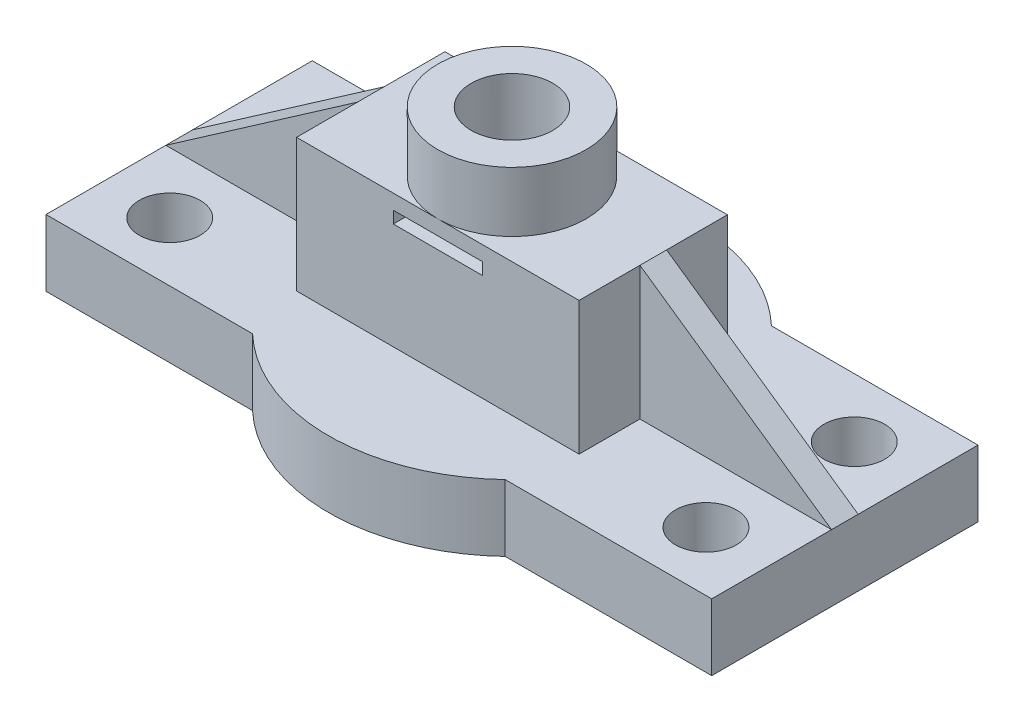
from build123d import *

# Parameters (mm, degrees)
SKETCH2_R           = 4.566933549
BOSS_EXTRUDE1_DEPTH = 10
SKETCH3_W           = 42.436263922
SKETCH3_H           = 22.27820436
BOSS_EXTRUDE2_DEPTH = 20
RIB2_REACH          = 66.498
SKETCH5_WALL_W      = 166.044941872
SKETCH5_WALL_H      = 4
BOSS_EXTRUDE3_DEPTH = 2
SKETCH7_R           = 11.13910218
SKETCH7_R_2         = 6.13910218
EXTRUDE_THIN1_DEPTH = 9
SKETCH9_R           = 6.13910218
CUT_EXTRUDE2_DEPTH  = 65.498231097
SKETCH12_R          = 10
CUT_EXTRUDE4_DEPTH  = 19
CUT_EXTRUDE4_DRAFT  = -11.5
SKETCH13_W          = 13.380488588
SKETCH13_H          = 1.799910433
CUT_EXTRUDE5_DEPTH  = 9


with BuildPart() as part:
    # Sketch2 → Boss-Extrude1 (new body)
    with BuildSketch(Plane(origin=(0, 0, 0), x_dir=(1, 0, 0), z_dir=(0, 1, 0))):
        with BuildLine():
            Line((-50, 20), (-18.974240817, 20))
            ThreePointArc((-18.974240817, 20), (0, 27.568493151), (18.974240817, 20))
            Line((18.974240817, 20), (50, 20))
            Line((50, 20), (50, -20))
            Line((50, -20), (18.974240817, -20))
            ThreePointArc((18.974240817, -20), (0, -27.568493151), (-18.974240817, -20))
            Line((-18.974240817, -20), (-50, -20))
            Line((-50, -20), (-50, 20))
        make_face()
        with Locations(Location((-40.274600864, 11.13910218, 0), (0, 0, 270))):
            Circle(SKETCH2_R, mode=Mode.SUBTRACT)
        with Locations(Location((-40.274600864, -11.13910218, 0), (0, 0, 90))):
            Circle(SKETCH2_R, mode=Mode.SUBTRACT)
        with Locations(Location((40.274600864, -11.13910218, 0), (0, 0, 270))):
            Circle(SKETCH2_R, mode=Mode.SUBTRACT)
        with Locations(Location((40.274600864, 11.13910218, 0), (0, 0, 90))):
            Circle(SKETCH2_R, mode=Mode.SUBTRACT)
    extrude(amount=BOSS_EXTRUDE1_DEPTH)

    # Sketch3 → Boss-Extrude2 (add)
    with BuildSketch(Plane(origin=(0, 10, 0), x_dir=(1, 0, 0), z_dir=(0, 1, 0))):
        Rectangle(SKETCH3_W, SKETCH3_H)
    extrude(amount=BOSS_EXTRUDE2_DEPTH)

    # Sketch5 wall → Rib2 (add, up to next)
    with BuildSketch(Plane(origin=(-35.60906598, 20, 0), x_dir=(-0.82120161281, -0.570638161288, 0), z_dir=(0.570638161288, -0.82120161281, 0)), mode=Mode.PRIVATE) as rib2_sk1:
        Rectangle(SKETCH5_WALL_W, SKETCH5_WALL_H)
    rib2_tool1 = extrude(rib2_sk1.sketch, amount=RIB2_REACH, mode=Mode.PRIVATE) - part.part
    add(rib2_tool1.solids().sort_by_distance((-35.60906598, 20, 0))[0])

    # Sketch6 → Boss-Extrude3 (add, symmetric)
    with BuildSketch(Plane.XY):
        Polygon((21.218131961, 30), (50, 10), (21.218131961, 10), align=None)
    extrude(amount=BOSS_EXTRUDE3_DEPTH, both=True)

    # Sketch7 → Extrude-Thin1 (add)
    with BuildSketch(Plane(origin=(0, 30, 0), x_dir=(1, 0, 0), z_dir=(0, 1, 0))):
        Circle(SKETCH7_R)
        Circle(SKETCH7_R_2, mode=Mode.SUBTRACT)
    extrude(amount=EXTRUDE_THIN1_DEPTH)

    # Sketch9 → Cut-Extrude2 (cut, through all)
    with BuildSketch(Plane(origin=(0, 30, 0), x_dir=(1, 0, 0), z_dir=(0, 1, 0))):
        Circle(SKETCH9_R)
    extrude(amount=-CUT_EXTRUDE2_DEPTH, mode=Mode.SUBTRACT)


with BuildPart() as cut_extrude4_tool:
    # Sketch12 → Cut-Extrude4 (with draft: the straight prism first)
    with BuildSketch(Plane.XZ):
        Circle(SKETCH12_R)
    extrude(amount=-CUT_EXTRUDE4_DEPTH)
    # Cut-Extrude4: the draft: its side faces are tilted about the plane it starts from
    cut_extrude4_sides = [cut_extrude4_tool.faces().sort_by_distance(p)[0] for p in [
        (-10, 9.5, 0),
    ]]
    draft(cut_extrude4_sides, Plane.XZ, CUT_EXTRUDE4_DRAFT)


with BuildPart() as part_1:
    add(part.part)

    # Cut-Extrude4: cut by cut_extrude4_tool
    add(cut_extrude4_tool.part, mode=Mode.SUBTRACT)

    # Sketch13 → Cut-Extrude5 (cut)
    with BuildSketch(Plane.XY.offset(11.13910218)):
        with Locations((0, 26.881553508)):
            Rectangle(SKETCH13_W, SKETCH13_H)
    extrude(amount=-CUT_EXTRUDE5_DEPTH, mode=Mode.SUBTRACT)


solid = part_1.part
